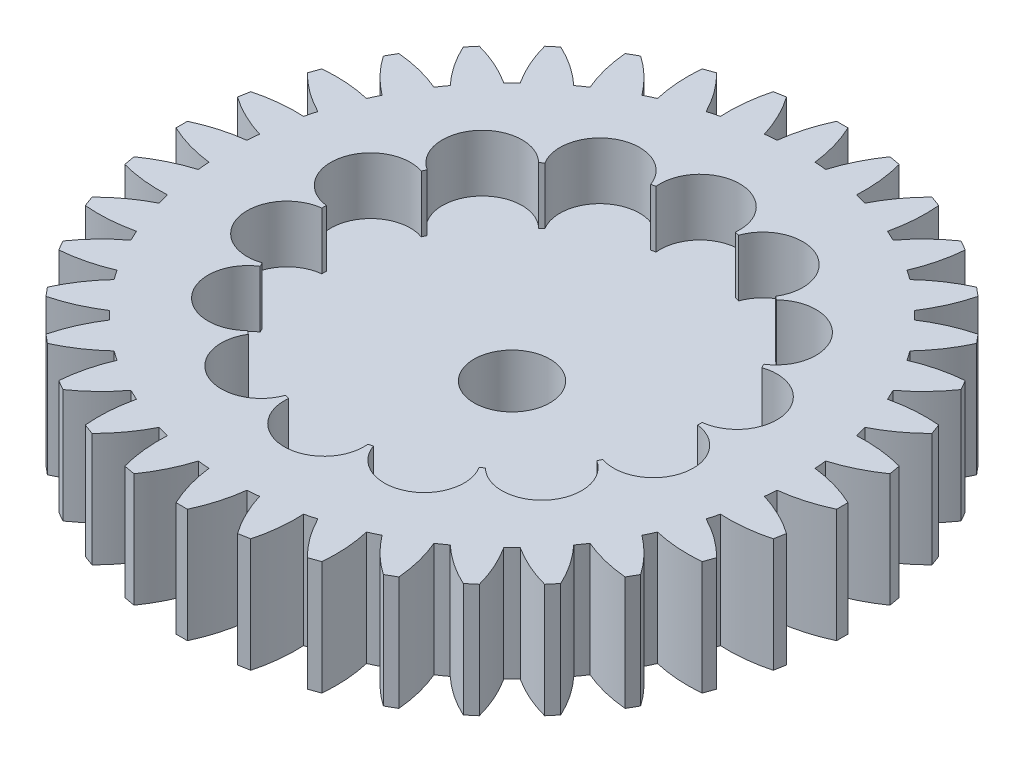
from build123d import *

# Parameters (mm, degrees)
SKETCH1_R               = 7.5
BOSS_EXTRUDE1_DEPTH     = 3
BOSS_EXTRUDE2_DEPTH     = 3
CIRPATTERN1_COUNT       = 36
SKETCH5_R               = 1.05
SKETCH5_R_2             = 4.95
CUT_EXTRUDE2_DEPTH      = 1.5
CIRPATTERN2_COUNT       = 14
SKETCH6_R               = 1
CUT_EXTRUDE3_DEPTH      = 2.5
CUT_EXTRUDE3_DEPTH_BACK = 2.5
CUT_EXTRUDE4_DEPTH      = 0.2


with BuildPart() as part:
    # Sketch1 → Boss-Extrude1 (new body)
    with BuildSketch(Plane(origin=(0, 0, 0), x_dir=(1, 0, 0), z_dir=(0, 1, 0))):
        Circle(SKETCH1_R)
    extrude(amount=BOSS_EXTRUDE1_DEPTH)

    # Sketch2 → Boss-Extrude2 (add, through all)
    with BuildSketch(Plane(origin=(0, 3, 0), x_dir=(1, 0, 0), z_dir=(0, 1, 0))):
        with BuildLine():
            Line((-0.15, 8.7), (0.15, 8.7))
            ThreePointArc((0.15, 8.7), (0.37344133, 8.105592351), (0.5, 7.483314774))
            ThreePointArc((0.5, 7.483314774), (0, 7.5), (-0.5, 7.483314774))
            ThreePointArc((-0.5, 7.483314774), (-0.37344133, 8.105592351), (-0.15, 8.7))
        make_face()
    boss_extrude2 = extrude(amount=-BOSS_EXTRUDE2_DEPTH)

    # CirPattern1: Boss-Extrude2 ×36 about axis
    cirpattern1_axis = Axis((0, 0, 0), (0, 1, 0))
    for i in range(1, CIRPATTERN1_COUNT):
        add(boss_extrude2.rotate(cirpattern1_axis, i * 360 / CIRPATTERN1_COUNT))

    # Sketch5 → Cut-Extrude2 (cut)
    with BuildSketch(Plane(origin=(0, 3, 0), x_dir=(1, 0, 0), z_dir=(0, 1, 0))):
        with Locations((0, 4.95)):
            Circle(SKETCH5_R)
        Circle(SKETCH5_R_2)
        Circle(SKETCH5_R_2)
        with Locations((0, 4.95)):
            Circle(SKETCH5_R)
        with Locations((0, 4.95)):
            Circle(SKETCH5_R)
        Circle(SKETCH5_R_2)
    cut_extrude2 = extrude(amount=-CUT_EXTRUDE2_DEPTH, mode=Mode.SUBTRACT)

    # CirPattern2: Cut-Extrude2 ×14 about axis
    cirpattern2_axis = Axis((0, 0, 0), (0, 1, 0))
    for i in range(1, CIRPATTERN2_COUNT):
        add(cut_extrude2.rotate(cirpattern2_axis, i * 360 / CIRPATTERN2_COUNT), mode=Mode.SUBTRACT)

    # Sketch6 → Cut-Extrude3 (cut, two sides)
    with BuildSketch(Plane(origin=(0, 1.5, 0), x_dir=(1, 0, 0), z_dir=(0, 1, 0))) as cut_extrude3_sk:
        Circle(SKETCH6_R)
    extrude(amount=CUT_EXTRUDE3_DEPTH, mode=Mode.SUBTRACT)
    extrude(cut_extrude3_sk.sketch, amount=-CUT_EXTRUDE3_DEPTH_BACK, mode=Mode.SUBTRACT)

    # Sketch7 → Cut-Extrude4 (cut)
    with BuildSketch(Plane.XZ):
        with BuildLine():
            Line((-0.2, 6.997142274), (-0.2, 7.29725976))
            ThreePointArc((-0.2, 7.29725976), (-5.161879503, 5.161879503), (-7.29725976, 0.2))
            Line((-7.29725976, 0.2), (-6.997142274, 0.2))
            ThreePointArc((-6.997142274, 0.2), (-4.949747468, 4.949747468), (-0.2, 6.997142274))
        make_face()
        with BuildLine():
            ThreePointArc((-7.29725976, -0.2), (-5.161879503, -5.161879503), (-0.2, -7.29725976))
            Line((-0.2, -7.29725976), (-0.2, -6.997142274))
            ThreePointArc((-0.2, -6.997142274), (-4.949747468, -4.949747468), (-6.997142274, -0.2))
            Line((-6.997142274, -0.2), (-7.29725976, -0.2))
        make_face()
        with BuildLine():
            ThreePointArc((0.2, -7.29725976), (5.161879503, -5.161879503), (7.29725976, -0.2))
            Line((7.29725976, -0.2), (6.997142274, -0.2))
            ThreePointArc((6.997142274, -0.2), (4.949747468, -4.949747468), (0.2, -6.997142274))
            Line((0.2, -6.997142274), (0.2, -7.29725976))
        make_face()
        with BuildLine():
            Line((6.997142274, 0.2), (7.29725976, 0.2))
            ThreePointArc((7.29725976, 0.2), (5.161879503, 5.161879503), (0.2, 7.29725976))
            Line((0.2, 7.29725976), (0.2, 6.997142274))
            ThreePointArc((0.2, 6.997142274), (4.949747468, 4.949747468), (6.997142274, 0.2))
        make_face()
    extrude(amount=-CUT_EXTRUDE4_DEPTH, mode=Mode.SUBTRACT)


solid = part.part
